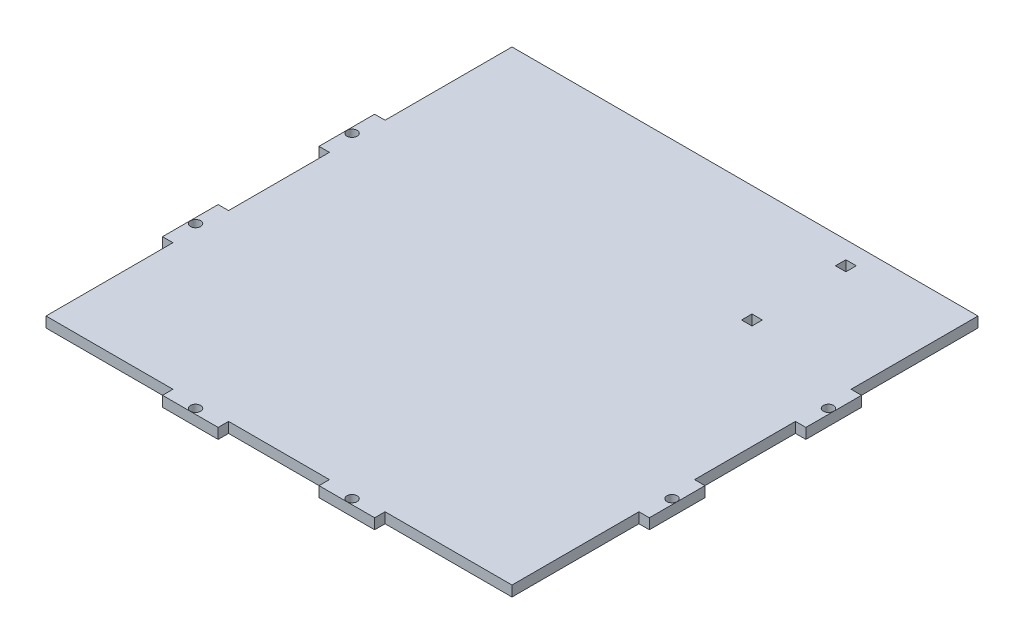
from build123d import *

# Parameters (mm, degrees)
BOSS_EXTRUDE1_DEPTH = 3
SKETCH2_W           = 3
SKETCH2_H           = 3
SKETCH2_H_2         = 36.5
SKETCH2_W_2         = 36.5
SKETCH2_W_3         = 29
SKETCH2_H_3         = 29
CUT_EXTRUDE2_DEPTH  = 3
SKETCH3_R           = 1.47
CUT_EXTRUDE3_DEPTH  = 3
SKETCH4_W           = 16
SKETCH4_H           = 3
CUT_EXTRUDE6_DEPTH  = 3
SKETCH6_W           = 16
SKETCH6_H           = 3
CUT_EXTRUDE7_DEPTH  = 3
SKETCH7_W           = 3
SKETCH7_H           = 3
CUT_EXTRUDE8_DEPTH  = 3


with BuildPart() as part:
    # Sketch1 → Boss-Extrude1 (new body)
    with BuildSketch(Plane(origin=(0, 0, 0), x_dir=(1, 0, 0), z_dir=(0, 1, 0))):
        Polygon((70, 70), (-70, 70), (0, 0), align=None)
        Polygon((0, 0), (-70, 70), (-70, -70), align=None)
        Polygon((70, -70), (0, 0), (-70, -70), align=None)
        Polygon((70, 70), (0, 0), (70, -70), align=None)
    extrude(amount=BOSS_EXTRUDE1_DEPTH)

    # Sketch2 → Cut-Extrude2 (cut)
    with BuildSketch(Plane(origin=(0, 3, 0), x_dir=(1, 0, 0), z_dir=(0, 1, 0))):
        with Locations((-68.5, 68.5)):
            Rectangle(SKETCH2_W, SKETCH2_H)
        with Locations((-68.5, 48.75)):
            Rectangle(SKETCH2_W, SKETCH2_H_2)
        with Locations((-48.75, 68.5)):
            Rectangle(SKETCH2_W_2, SKETCH2_H)
        with Locations((48.75, 68.5)):
            Rectangle(SKETCH2_W_2, SKETCH2_H)
        with Locations((68.5, 68.5)):
            Rectangle(SKETCH2_W, SKETCH2_H)
        with Locations((68.5, 48.75)):
            Rectangle(SKETCH2_W, SKETCH2_H_2)
        with Locations((68.5, -68.5)):
            Rectangle(SKETCH2_W, SKETCH2_H)
        with Locations((68.5, -48.75)):
            Rectangle(SKETCH2_W, SKETCH2_H_2)
        with Locations((48.75, -68.5)):
            Rectangle(SKETCH2_W_2, SKETCH2_H)
        with Locations((-48.75, -68.5)):
            Rectangle(SKETCH2_W_2, SKETCH2_H)
        with Locations((-68.5, -68.5)):
            Rectangle(SKETCH2_W, SKETCH2_H)
        with Locations((-68.5, -48.75)):
            Rectangle(SKETCH2_W, SKETCH2_H_2)
        with Locations((0, 68.5)):
            Rectangle(SKETCH2_W_3, SKETCH2_H)
        with Locations((0, -68.5)):
            Rectangle(SKETCH2_W_3, SKETCH2_H)
        with Locations((68.5, 0)):
            Rectangle(SKETCH2_W, SKETCH2_H_3)
        with Locations((-68.5, 0)):
            Rectangle(SKETCH2_W, SKETCH2_H_3)
    extrude(amount=-CUT_EXTRUDE2_DEPTH, mode=Mode.SUBTRACT)

    # Sketch3 → Cut-Extrude3 (cut)
    with BuildSketch(Plane(origin=(0, 3, 0), x_dir=(1, 0, 0), z_dir=(0, 1, 0))):
        with Locations((22.5, -68.5)):
            Circle(SKETCH3_R)
        with Locations((-22.5, -68.5)):
            Circle(SKETCH3_R)
        with Locations((-22.5, 68.5)):
            Circle(SKETCH3_R)
        with Locations((22.5, 68.5)):
            Circle(SKETCH3_R)
        with Locations((68.5, -22.5)):
            Circle(SKETCH3_R)
        with Locations((-68.5, -22.5)):
            Circle(SKETCH3_R)
        with Locations((-68.5, 22.5)):
            Circle(SKETCH3_R)
        with Locations((68.5, 22.5)):
            Circle(SKETCH3_R)
    extrude(amount=-CUT_EXTRUDE3_DEPTH, mode=Mode.SUBTRACT)

    # Sketch4 → Cut-Extrude6 (cut)
    with BuildSketch(Plane(origin=(0, 3, 0), x_dir=(1, 0, 0), z_dir=(0, 1, 0))):
        with Locations((22.5, 68.5)):
            Rectangle(SKETCH4_W, SKETCH4_H)
    extrude(amount=-CUT_EXTRUDE6_DEPTH, mode=Mode.SUBTRACT)

    # Sketch6 → Cut-Extrude7 (cut)
    with BuildSketch(Plane(origin=(0, 3, 0), x_dir=(1, 0, 0), z_dir=(0, 1, 0))):
        with Locations((-22.5, 68.5)):
            Rectangle(SKETCH6_W, SKETCH6_H)
    extrude(amount=-CUT_EXTRUDE7_DEPTH, mode=Mode.SUBTRACT)

    # Sketch7 → Cut-Extrude8 (cut)
    with BuildSketch(Plane(origin=(0, 3, 0), x_dir=(1, 0, 0), z_dir=(0, 1, 0))):
        with Locations((35.5, 33.5)):
            Rectangle(SKETCH7_W, SKETCH7_H)
        with Locations((35.5, 60.5)):
            Rectangle(SKETCH7_W, SKETCH7_H)
    extrude(amount=-CUT_EXTRUDE8_DEPTH, mode=Mode.SUBTRACT)


solid = part.part
